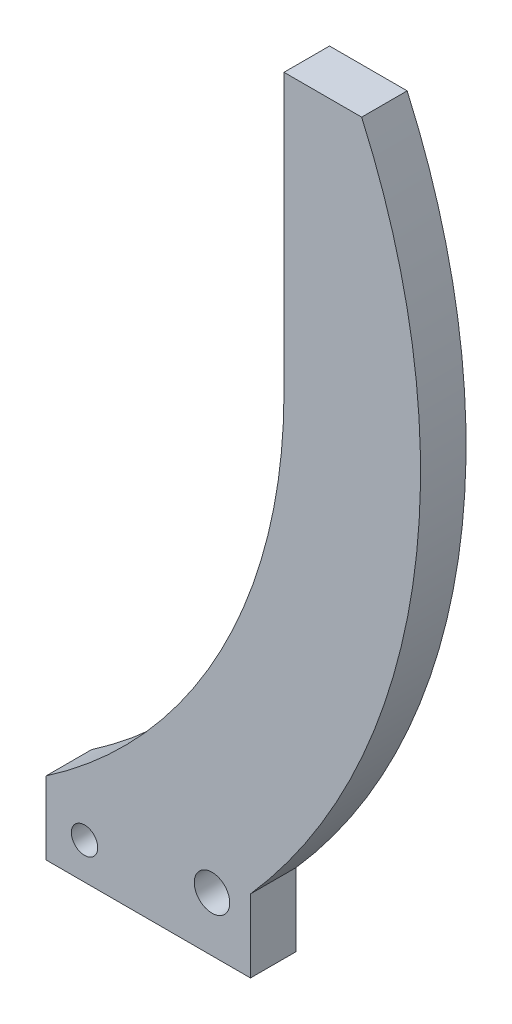
from build123d import *

# Parameters (mm, degrees)
SKETCH1_R           = 1.45
SKETCH1_R_2         = 1.95
BOSS_EXTRUDE1_DEPTH = 5


with BuildPart() as part:
    # Sketch1 → Boss-Extrude1 (new body)
    with BuildSketch(Plane.XY):
        with BuildLine():
            Line((60, 30.470821026), (68.531226941, 30.470821026))
            ThreePointArc((68.531226941, 30.470821026), (74.141161233, -11.317606244), (56.31927228, -49.529178974))
            Line((56.31927228, -49.529178974), (56.31927228, -57.529178974))
            Line((56.31927228, -57.529178974), (33.865327846, -57.529178974))
            Line((33.865327846, -57.529178974), (33.865327846, -49.529178974))
            ThreePointArc((33.865327846, -49.529178974), (53.065618204, -28.000717216), (60, 0))
            Line((60, 0), (60, 30.470821026))
        make_face()
        with Locations((38.092300063, -53.529178974)):
            Circle(SKETCH1_R, mode=Mode.SUBTRACT)
        with Locations((52.092300063, -51.529178974)):
            Circle(SKETCH1_R_2, mode=Mode.SUBTRACT)
    extrude(amount=BOSS_EXTRUDE1_DEPTH)


solid = part.part
